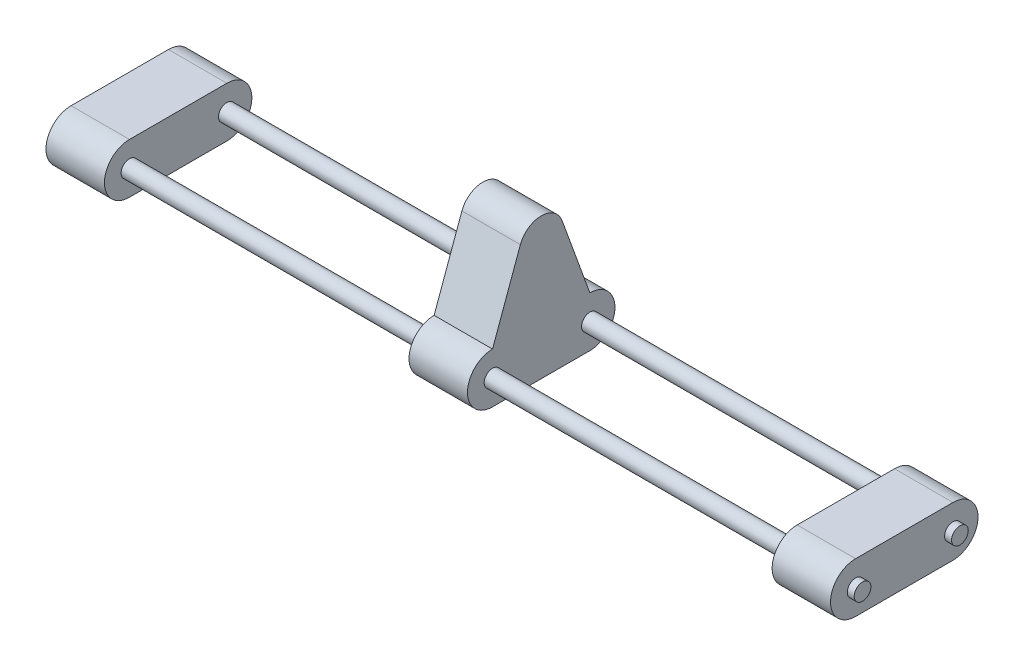
from build123d import *

# Parameters (mm, degrees)
IZIM1_R                          = 6
Y_KSEKLIK_EKSTR_ZYON1_DEPTH      = 21
IZIM2_R                          = 6
Y_KSEKLIK_EKSTR_ZYON2_DEPTH      = 21
IZIM3_R                          = 6
Y_KSEKLIK_EKSTR_ZYON3_DEPTH      = 287
Y_KSEKLIK_EKSTR_ZYON3_DEPTH_BACK = 287
Y_KSEKLIK_EKSTR_ZYON4_DEPTH      = 42


with BuildPart() as part:
    # Çizim1 → Yükseklik-Ekstrüzyon1 (new body, symmetric)
    with BuildSketch(Plane(origin=(0, 0, 0), x_dir=(0, 0, -1), z_dir=(1, 0, 0))):
        with BuildLine():
            Line((-35, 18), (35, 18))
            ThreePointArc((35, 18), (53, 0), (35, -18))
            Line((35, -18), (-35, -18))
            ThreePointArc((-35, -18), (-53, 0), (-35, 18))
        make_face()
        with Locations((-35, 0)):
            Circle(IZIM1_R, mode=Mode.SUBTRACT)
        with Locations((35, 0)):
            Circle(IZIM1_R, mode=Mode.SUBTRACT)
    extrude(amount=Y_KSEKLIK_EKSTR_ZYON1_DEPTH, both=True)


with BuildPart() as body_2:
    # Çizim2 → Yükseklik-Ekstrüzyon2 (new body, symmetric)
    with BuildSketch(Plane.ZY.offset(261)):
        with BuildLine():
            Line((15, 73), (-15, 73))
            Line((-15, 73), (-35, 18))
            ThreePointArc((-35, 18), (-53, 0), (-35, -18))
            Line((-35, -18), (35, -18))
            ThreePointArc((35, -18), (53, 0), (35, 18))
            Line((35, 18), (15, 73))
        make_face()
        with Locations((35, 0)):
            Circle(IZIM2_R, mode=Mode.SUBTRACT)
        with Locations((-35, 0)):
            Circle(IZIM2_R, mode=Mode.SUBTRACT)
    extrude(amount=Y_KSEKLIK_EKSTR_ZYON2_DEPTH, both=True)


with BuildPart() as body_3:
    # Aynalama1: mirrored copy
    add(part.part.mirror(Plane.ZY.offset(261)))


with BuildPart() as part_1:
    add(part.part)

    add(body_2.part)  # Yükseklik-Ekstrüzyon3 merges body 2

    add(body_3.part)  # Yükseklik-Ekstrüzyon3 merges body 3
    # Çizim3 → Yükseklik-Ekstrüzyon3 (add, two sides)
    with BuildSketch(Plane.ZY.offset(261)) as y_kseklik_ekstr_zyon3_sk:
        with Locations((-35, 0)):
            Circle(IZIM3_R)
        with Locations((35, 0)):
            Circle(IZIM3_R)
    extrude(amount=Y_KSEKLIK_EKSTR_ZYON3_DEPTH)
    extrude(y_kseklik_ekstr_zyon3_sk.sketch, amount=-Y_KSEKLIK_EKSTR_ZYON3_DEPTH_BACK)

    # Çizim4 → Yükseklik-Ekstrüzyon4 (add)
    with BuildSketch(Plane(origin=(-240, 0, 0), x_dir=(0, 0, -1), z_dir=(1, 0, 0))):
        with BuildLine():
            ThreePointArc((-15, 73), (0, 83.446627943), (15, 73))
            Line((15, 73), (-15, 73))
        make_face()
    extrude(amount=-Y_KSEKLIK_EKSTR_ZYON4_DEPTH)


solid = part_1.part
